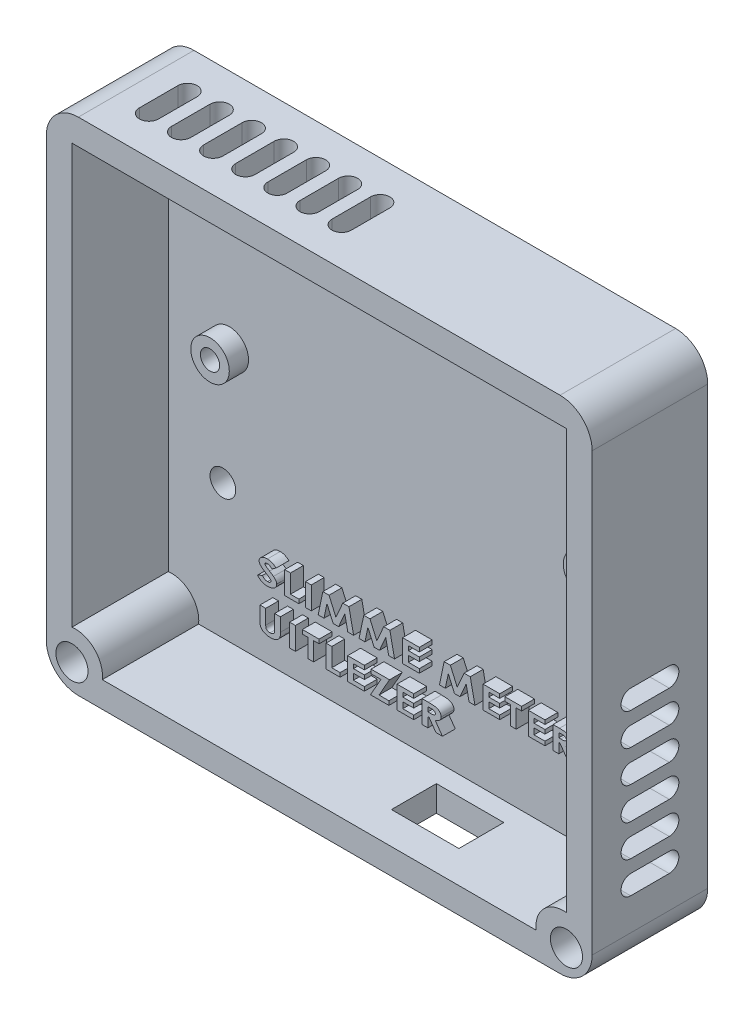
from build123d import *

# Parameters (mm, degrees)
SKETCH1_W                     = 85
SKETCH1_H                     = 78
SKETCH1_R                     = 1.5
BASE_PLATE_DEPTH              = 3
SKETCH2_R                     = 3
SKETCH2_R_2                   = 1.5
PI_ZERO_STAANDERS_DEPTH       = 3
SKETCH3_W                     = 85
SKETCH3_H                     = 78
SKETCH3_W_2                   = 77
SKETCH3_H_2                   = 70
BASE_WALLS_DEPTH              = 15
SKETCH5_W                     = 10.5
SKETCH5_H                     = 7
USB_POWER_UITSNEDE_DEPTH      = 4
FILLET1_R                     = 5
FILLET2_R                     = 5
FILLET3_R                     = 5
FILLET4_R                     = 5
LUCHT_VENTILATIE_RECHTS_DEPTH = 4
SKETCH10_R                    = 2
HOLES_FOR_SCREW_DEPTH         = 4
COOL_HOLES_DEPTH              = 4
SKETCH15_R                    = 4.25
SKETCH15_R_2                  = 1.475
SCREW_HOLES_DEPTH             = 15
SKETCH17_W                    = 0.897435898
SKETCH17_H                    = 3.5
SKETCH17_W_2                  = 0.897435897
TEKST_DEPTH                   = 2
SKETCH18_W                    = 15
SKETCH18_H                    = 2.5
CUT_EXTRUDE1_DEPTH            = 2.5
SKETCH19_R                    = 2.5
CUT_EXTRUDE2_DEPTH            = 16


with BuildPart() as part:
    # Sketch1 → Base Plate (new body)
    with BuildSketch(Plane.XY):
        with Locations((32.5, -1)):
            Rectangle(SKETCH1_W, SKETCH1_H)
        with BuildLine():
            Line((0, 3), (0, 27))
            ThreePointArc((0, 27), (0.878679656, 29.121320344), (3, 30))
            Line((3, 30), (62, 30))
            ThreePointArc((62, 30), (64.121320344, 29.121320344), (65, 27))
            Line((65, 27), (65, 3))
            ThreePointArc((65, 3), (64.121320344, 0.878679656), (62, 0))
            Line((62, 0), (3, 0))
            ThreePointArc((3, 0), (0.878679656, 0.878679656), (0, 3))
        make_face(mode=Mode.SUBTRACT)
        with BuildLine():
            ThreePointArc((0, 27), (0.878679656, 29.121320344), (3, 30))
            Line((3, 30), (62, 30))
            ThreePointArc((62, 30), (64.121320344, 29.121320344), (65, 27))
            Line((65, 27), (65, 3))
            ThreePointArc((65, 3), (64.121320344, 0.878679656), (62, 0))
            Line((62, 0), (3, 0))
            ThreePointArc((3, 0), (0.878679656, 0.878679656), (0, 3))
            Line((0, 3), (0, 27))
        make_face()
        with Locations((61.5, 26.5)):
            Circle(SKETCH1_R, mode=Mode.SUBTRACT)
        with Locations((3.5, 26.5)):
            Circle(SKETCH1_R, mode=Mode.SUBTRACT)
        with Locations((61.5, 3.5)):
            Circle(SKETCH1_R, mode=Mode.SUBTRACT)
        with Locations((3.5, 3.5)):
            Circle(SKETCH1_R, mode=Mode.SUBTRACT)
    extrude(amount=BASE_PLATE_DEPTH)

    # Sketch2 → Pi Zero Staanders (add)
    with BuildSketch(Plane.XY.offset(3)):
        with Locations((3.5, 26.5)):
            Circle(SKETCH2_R)
        with Locations((3.5, 26.5)):
            Circle(SKETCH2_R_2, mode=Mode.SUBTRACT)
        with Locations((3.5, 3.5)):
            Circle(SKETCH2_R)
        with Locations((3.5, 3.5)):
            Circle(SKETCH2_R_2, mode=Mode.SUBTRACT)
        with Locations((61.5, 26.5)):
            Circle(SKETCH2_R)
        with Locations((61.5, 26.5)):
            Circle(SKETCH2_R_2, mode=Mode.SUBTRACT)
        with Locations((61.5, 3.5)):
            Circle(SKETCH2_R)
        with Locations((61.5, 3.5)):
            Circle(SKETCH2_R_2, mode=Mode.SUBTRACT)
    extrude(amount=PI_ZERO_STAANDERS_DEPTH)

    # Sketch3 → Base Walls (add)
    with BuildSketch(Plane.XY.offset(3)):
        with Locations((32.5, -1)):
            Rectangle(SKETCH3_W, SKETCH3_H)
        with Locations((32.5, -1)):
            Rectangle(SKETCH3_W_2, SKETCH3_H_2, mode=Mode.SUBTRACT)
    extrude(amount=BASE_WALLS_DEPTH)

    # Sketch5 → USB Power uitsnede (cut)
    with BuildSketch(Plane.XZ.offset(40)):
        with Locations((44, 9.5)):
            Rectangle(SKETCH5_W, SKETCH5_H)
    extrude(amount=-USB_POWER_UITSNEDE_DEPTH, mode=Mode.SUBTRACT)

    # Fillet1
    fillet1_edges = [part.edges().sort_by_distance(p)[0] for p in [
        (75, 38, 9),
    ]]
    fillet(fillet1_edges, radius=FILLET1_R)

    # Fillet2
    fillet2_edges = [part.edges().sort_by_distance(p)[0] for p in [
        (-10, 38, 9),
    ]]
    fillet(fillet2_edges, radius=FILLET2_R)

    # Fillet3
    fillet3_edges = [part.edges().sort_by_distance(p)[0] for p in [
        (-10, -40, 9),
    ]]
    fillet(fillet3_edges, radius=FILLET3_R)

    # Fillet4
    fillet4_edges = [part.edges().sort_by_distance(p)[0] for p in [
        (75, -40, 9),
    ]]
    fillet(fillet4_edges, radius=FILLET4_R)

    # Sketch9 → Lucht ventilatie Rechts (cut)
    with BuildSketch(Plane(origin=(75, 0, 0), x_dir=(0, 0, -1), z_dir=(1, 0, 0))):
        with BuildLine():
            Line((-12, -27), (-6, -27))
            ThreePointArc((-6, -27), (-4.5, -28.5), (-6, -30))
            Line((-6, -30), (-12, -30))
            ThreePointArc((-12, -30), (-13.5, -28.5), (-12, -27))
        make_face()
        with BuildLine():
            Line((-12, -22), (-6, -22))
            ThreePointArc((-6, -22), (-4.5, -23.5), (-6, -25))
            Line((-6, -25), (-12, -25))
            ThreePointArc((-12, -25), (-13.5, -23.5), (-12, -22))
        make_face()
        with BuildLine():
            Line((-12, -17), (-6, -17))
            ThreePointArc((-6, -17), (-4.5, -18.5), (-6, -20))
            Line((-6, -20), (-12, -20))
            ThreePointArc((-12, -20), (-13.5, -18.5), (-12, -17))
        make_face()
        with BuildLine():
            Line((-12, -12), (-6, -12))
            ThreePointArc((-6, -12), (-4.5, -13.5), (-6, -15))
            Line((-6, -15), (-12, -15))
            ThreePointArc((-12, -15), (-13.5, -13.5), (-12, -12))
        make_face()
        with BuildLine():
            Line((-12, -7), (-6, -7))
            ThreePointArc((-6, -7), (-4.5, -8.5), (-6, -10))
            Line((-6, -10), (-12, -10))
            ThreePointArc((-12, -10), (-13.5, -8.5), (-12, -7))
        make_face()
        with BuildLine():
            Line((-12, -2), (-6, -2))
            ThreePointArc((-6, -2), (-4.5, -3.5), (-6, -5))
            Line((-6, -5), (-12, -5))
            ThreePointArc((-12, -5), (-13.5, -3.5), (-12, -2))
        make_face()
    extrude(amount=-LUCHT_VENTILATIE_RECHTS_DEPTH, mode=Mode.SUBTRACT)

    # Sketch10 → Holes for screw (cut, through all)
    with BuildSketch(Plane.XY.offset(3)):
        with Locations((2.5, -15.071619109)):
            Circle(SKETCH10_R)
        with Locations((62.5, -15.071619109)):
            Circle(SKETCH10_R)
    extrude(amount=-HOLES_FOR_SCREW_DEPTH, mode=Mode.SUBTRACT)

    # Sketch11 → Cool holes (cut)
    with BuildSketch(Plane(origin=(0, 38, 0), x_dir=(1, 0, 0), z_dir=(0, 1, 0))):
        with BuildLine():
            Line((-1.5, -12), (-1.5, -6))
            ThreePointArc((-1.5, -6), (0, -4.5), (1.5, -6))
            Line((1.5, -6), (1.5, -12))
            ThreePointArc((1.5, -12), (0, -13.5), (-1.5, -12))
        make_face()
        with BuildLine():
            Line((6.5, -12), (6.5, -6))
            ThreePointArc((6.5, -6), (5, -4.5), (3.5, -6))
            Line((3.5, -6), (3.5, -12))
            ThreePointArc((3.5, -12), (5, -13.5), (6.5, -12))
        make_face()
        with BuildLine():
            Line((11.5, -12), (11.5, -6))
            ThreePointArc((11.5, -6), (10, -4.5), (8.5, -6))
            Line((8.5, -6), (8.5, -12))
            ThreePointArc((8.5, -12), (10, -13.5), (11.5, -12))
        make_face()
        with BuildLine():
            Line((16.5, -12), (16.5, -6))
            ThreePointArc((16.5, -6), (15, -4.5), (13.5, -6))
            Line((13.5, -6), (13.5, -12))
            ThreePointArc((13.5, -12), (15, -13.5), (16.5, -12))
        make_face()
        with BuildLine():
            Line((21.5, -12), (21.5, -6))
            ThreePointArc((21.5, -6), (20, -4.5), (18.5, -6))
            Line((18.5, -6), (18.5, -12))
            ThreePointArc((18.5, -12), (20, -13.5), (21.5, -12))
        make_face()
        with BuildLine():
            Line((26.5, -12), (26.5, -6))
            ThreePointArc((26.5, -6), (25, -4.5), (23.5, -6))
            Line((23.5, -6), (23.5, -12))
            ThreePointArc((23.5, -12), (25, -13.5), (26.5, -12))
        make_face()
        with BuildLine():
            Line((31.5, -12), (31.5, -6))
            ThreePointArc((31.5, -6), (30, -4.5), (28.5, -6))
            Line((28.5, -6), (28.5, -12))
            ThreePointArc((28.5, -12), (30, -13.5), (31.5, -12))
        make_face()
    extrude(amount=-COOL_HOLES_DEPTH, mode=Mode.SUBTRACT)

    # Sketch15 → Screw Holes (add, through all)
    with BuildSketch(Plane.XY.offset(3)):
        with Locations((-5.5, -35.5)):
            Circle(SKETCH15_R)
        with Locations((-5.5, -35.5)):
            Circle(SKETCH15_R_2, mode=Mode.SUBTRACT)
        with Locations((70.5, -35.5)):
            Circle(SKETCH15_R)
        with Locations((70.5, -35.5)):
            Circle(SKETCH15_R_2, mode=Mode.SUBTRACT)
    extrude(amount=SCREW_HOLES_DEPTH)

    # Sketch17 → Tekst (add)
    with BuildSketch(Plane.XY.offset(3)):
        with BuildLine():
            Line((12.788368786, -20.420158139), (12.134222152, -20.8499458))
            add(Edge.make_bspline(
                [(12.134222152, -20.8499458), (12.105916214, -20.821431379), (12.050951664, -20.766061998), (11.963694483, -20.693193421), (11.876664006, -20.631001147), (11.789160013, -20.579670357), (11.700677894, -20.540288503), (11.611836758, -20.511997558), (11.522617657, -20.494221574), (11.462860439, -20.49205195), (11.433100357, -20.490971441)],
                knots=[0, 0, 0, 0, 0.000120481, 0.00023395, 0.000340557, 0.00044109, 0.000537763, 0.000630449, 0.000720379, 0.000809598, 0.000809598, 0.000809598, 0.000809598], degree=3))
            add(Edge.make_bspline(
                [(11.433100357, -20.490971441), (11.405466117, -20.491654327), (11.352414558, -20.492965316), (11.276603274, -20.506363161), (11.208550228, -20.528785971), (11.149327525, -20.559093295), (11.101410585, -20.594970072), (11.06484113, -20.633241503), (11.042918225, -20.675916041), (11.039853813, -20.705770617), (11.038368786, -20.720238268)],
                knots=[0, 0, 0, 0, 8.2839e-05, 0.000159033, 0.000229981, 0.000297088, 0.000357665, 0.000408789, 0.000454882, 0.000498222, 0.000498222, 0.000498222, 0.000498222], degree=3))
            add(Edge.make_bspline(
                [(11.038368786, -20.720238268), (11.039348383, -20.734844624), (11.041340854, -20.764553547), (11.057001056, -20.808208948), (11.082844522, -20.849964256), (11.105692489, -20.874844542), (11.117595549, -20.887806377)],
                knots=[0, 0, 0, 0, 4.3746e-05, 8.8978e-05, 0.000137436, 0.000190137, 0.000190137, 0.000190137, 0.000190137], degree=3))
            add(Edge.make_bspline(
                [(11.117595549, -20.887806377), (11.128669294, -20.89802759), (11.154557834, -20.921923056), (11.203176538, -20.958195785), (11.26361029, -21.004046625), (11.338514249, -21.056430713), (11.426515161, -21.116660228), (11.52870436, -21.183654088), (11.643319808, -21.259832032), (11.725137301, -21.311900521), (11.768236575, -21.339328812)],
                knots=[0, 0, 0, 0, 4.5183e-05, 0.00010563, 0.000181772, 0.000272813, 0.00037977, 0.000501695, 0.000639372, 0.000792627, 0.000792627, 0.000792627, 0.000792627], degree=3))
            add(Edge.make_bspline(
                [(11.768236575, -21.339328812), (11.808429466, -21.364810001), (11.884652078, -21.413133043), (11.992921082, -21.481617726), (12.0880721, -21.543756962), (12.171650258, -21.597044974), (12.241745962, -21.644526521), (12.300150365, -21.683703964), (12.346242598, -21.715351257), (12.37218663, -21.734925618), (12.383120389, -21.743174966)],
                knots=[0, 0, 0, 0, 0.000142769, 0.00027075, 0.000384323, 0.0004837, 0.000568094, 0.000638294, 0.000694698, 0.000735784, 0.000735784, 0.000735784, 0.000735784], degree=3))
            add(Edge.make_bspline(
                [(12.383120389, -21.743174966), (12.425227909, -21.776459178), (12.505352152, -21.839793999), (12.611420245, -21.939149829), (12.698531898, -22.036109743), (12.766093181, -22.132869437), (12.815999419, -22.231067786), (12.852784619, -22.331814659), (12.874065283, -22.437560088), (12.876756502, -22.509643027), (12.878112376, -22.545959421)],
                knots=[0, 0, 0, 0, 0.000160967, 0.000306295, 0.000435439, 0.000551351, 0.000659217, 0.000765002, 0.000872253, 0.000981153, 0.000981153, 0.000981153, 0.000981153], degree=3))
            add(Edge.make_bspline(
                [(12.878112376, -22.545959421), (12.876975922, -22.581347368), (12.874738763, -22.651010027), (12.854704867, -22.752861912), (12.824582363, -22.850458192), (12.779125936, -22.942273299), (12.722744754, -23.030216451), (12.652916809, -23.112809117), (12.570486179, -23.190376795), (12.477075351, -23.262737211), (12.373482538, -23.328299489), (12.261673913, -23.386024456), (12.141940626, -23.434433798), (12.014459102, -23.473502675), (11.879680457, -23.50416949), (11.737307353, -23.526659414), (11.587374634, -23.540092187), (11.484777531, -23.541523018), (11.432399235, -23.542253492)],
                knots=[0, 0, 0, 0, 0.000106057, 0.000208778, 0.000310332, 0.000411617, 0.000515079, 0.000623072, 0.000735155, 0.000854082, 0.000977008, 0.001102439, 0.001231073, 0.001363911, 0.001502016, 0.001645409, 0.001796039, 0.001953147, 0.001953147, 0.001953147, 0.001953147], degree=3))
            add(Edge.make_bspline(
                [(11.432399235, -23.542253492), (11.391252246, -23.541727972), (11.310039247, -23.540690738), (11.190229321, -23.532085671), (11.074377807, -23.518204189), (10.962708074, -23.498631063), (10.855038574, -23.473306618), (10.751261949, -23.442595364), (10.651495121, -23.406088678), (10.555586962, -23.363934965), (10.463527843, -23.315414657), (10.374973774, -23.260596032), (10.289966581, -23.199418612), (10.208185492, -23.13175347), (10.130058266, -23.057421686), (10.054521565, -22.97723656), (9.982935643, -22.890259727), (9.938877546, -22.828317951), (9.916573915, -22.796961024)],
                knots=[0, 0, 0, 0, 0.000123429, 0.000243616, 0.000360148, 0.000473342, 0.000583543, 0.000691797, 0.000797822, 0.000902042, 0.001005851, 0.001109749, 0.001214237, 0.001319807, 0.001427925, 0.001537545, 0.001650118, 0.001765533, 0.001765533, 0.001765533, 0.001765533], degree=3))
            Line((9.916573915, -22.796961024), (10.663969748, -22.465330415))
            add(Edge.make_bspline(
                [(10.663969748, -22.465330415), (10.692084405, -22.500928552), (10.746539267, -22.569878056), (10.836126775, -22.661340993), (10.928219985, -22.73946319), (11.02413009, -22.803220143), (11.123527353, -22.852772872), (11.226229705, -22.888192408), (11.332148831, -22.910057233), (11.404018456, -22.912714085), (11.440111575, -22.914048364)],
                knots=[0, 0, 0, 0, 0.000136005, 0.000263426, 0.000383359, 0.0004977, 0.00060807, 0.000715607, 0.000822858, 0.000931058, 0.000931058, 0.000931058, 0.000931058], degree=3))
            add(Edge.make_bspline(
                [(11.440111575, -22.914048364), (11.476907654, -22.912982622), (11.547754896, -22.910930642), (11.649251927, -22.891135297), (11.742392877, -22.861282613), (11.823270557, -22.81660095), (11.892156834, -22.766878122), (11.942075268, -22.709601268), (11.97498129, -22.647964535), (11.978796728, -22.604052093), (11.980676479, -22.582417755)],
                knots=[0, 0, 0, 0, 0.000110257, 0.000212289, 0.000309178, 0.000402346, 0.000488444, 0.000562514, 0.000628988, 0.000693541, 0.000693541, 0.000693541, 0.000693541], degree=3))
            add(Edge.make_bspline(
                [(11.980676479, -22.582417755), (11.979376133, -22.562338304), (11.976695861, -22.520950559), (11.951824217, -22.460460034), (11.914782914, -22.399868315), (11.87124146, -22.351145108), (11.827186512, -22.309964914), (11.784209708, -22.274639332), (11.733123331, -22.234427091), (11.672517578, -22.191411123), (11.603716064, -22.143520364), (11.526000304, -22.091665133), (11.438933833, -22.036586942), (11.377968021, -21.998580443), (11.346161254, -21.978751889)],
                knots=[0, 0, 0, 0, 6.0006e-05, 0.000123685, 0.000193548, 0.000272563, 0.000318694, 0.000374441, 0.000439377, 0.000513709, 0.00059734, 0.000690873, 0.000793957, 0.000906401, 0.000906401, 0.000906401, 0.000906401], degree=3))
            add(Edge.make_bspline(
                [(11.346161254, -21.978751889), (11.285546718, -21.941026987), (11.169234017, -21.868637003), (11.003683493, -21.762620192), (10.855450698, -21.662019307), (10.723781571, -21.568661292), (10.609183865, -21.481691843), (10.511185398, -21.401743277), (10.429645369, -21.328834771), (10.363700027, -21.2606673), (10.310966966, -21.195224797), (10.265494369, -21.13171828), (10.226841103, -21.068404548), (10.195761386, -21.004434416), (10.170808291, -20.941068871), (10.154239905, -20.877214925), (10.142930913, -20.813888841), (10.141596192, -20.771467988), (10.140932889, -20.750386505)],
                knots=[0, 0, 0, 0, 0.000214187, 0.000411001, 0.000589711, 0.000751578, 0.000895171, 0.001021211, 0.001130912, 0.001223146, 0.00130538, 0.001382809, 0.001457359, 0.001527598, 0.001595956, 0.001661262, 0.001725233, 0.001788432, 0.001788432, 0.001788432, 0.001788432], degree=3))
            add(Edge.make_bspline(
                [(10.140932889, -20.750386505), (10.141926567, -20.720383086), (10.143892734, -20.661016047), (10.162241958, -20.573689681), (10.191860643, -20.48983348), (10.232985486, -20.409278646), (10.285628443, -20.332155422), (10.349860691, -20.258292785), (10.426200062, -20.188327897), (10.512732211, -20.122082863), (10.607983464, -20.062011422), (10.709215507, -20.008165009), (10.816408526, -19.963485551), (10.928812094, -19.926080203), (11.04680702, -19.897526489), (11.170065622, -19.877224797), (11.29871462, -19.865259522), (11.386333648, -19.863608111), (11.430996992, -19.862766312)],
                knots=[0, 0, 0, 0, 8.9919e-05, 0.00017792, 0.000266398, 0.000356075, 0.000448445, 0.000545863, 0.000649059, 0.00075858, 0.000872365, 0.000986526, 0.001102158, 0.001220331, 0.001341577, 0.001465946, 0.001594804, 0.001728784, 0.001728784, 0.001728784, 0.001728784], degree=3))
            add(Edge.make_bspline(
                [(11.430996992, -19.862766312), (11.489033088, -19.864251496), (11.603906276, -19.867191181), (11.773982166, -19.890618358), (11.939847409, -19.927255984), (12.074819131, -19.97178314), (12.182034027, -20.015282681), (12.264170374, -20.054709724), (12.347504196, -20.100832373), (12.433381528, -20.151378226), (12.519360417, -20.210712101), (12.608503993, -20.273720408), (12.698382947, -20.344419212), (12.757897554, -20.394511232), (12.788368786, -20.420158139)],
                knots=[0, 0, 0, 0, 0.000174049, 0.000344503, 0.000514089, 0.000683037, 0.00077014, 0.000861083, 0.000956152, 0.001055832, 0.001159868, 0.001269409, 0.001383293, 0.001502776, 0.001502776, 0.001502776, 0.001502776], degree=3))
        make_face()
        Polygon((14.134522633, -19.952509902), (15.03195853, -19.952509902), (15.03195853, -22.824304774), (16.333240581, -22.824304774), (16.333240581, -23.452509902), (14.134522633, -23.452509902), align=None)
        with Locations((17.814009812, -21.702509902)):
            Rectangle(SKETCH17_W, SKETCH17_H)
        Polygon((20.066013017, -19.952509902), (21.032859972, -19.952509902), (22.099266222, -22.393815992), (23.171982568, -19.952509902), (24.131818306, -19.952509902), (24.858881607, -23.452509902), (23.949526639, -23.452509902), (23.490291863, -21.241872883), (22.518537056, -23.452509902), (21.674386415, -23.452509902), (20.708240581, -21.241872883), (20.249706927, -23.452509902), (19.339650838, -23.452509902), align=None)
        Polygon((26.437807889, -19.952509902), (27.404654844, -19.952509902), (28.471061094, -22.393815992), (29.54377744, -19.952509902), (30.503613177, -19.952509902), (31.230676479, -23.452509902), (30.321321511, -23.452509902), (29.862086735, -21.241872883), (28.890331927, -23.452509902), (28.046181286, -23.452509902), (27.080035453, -21.241872883), (26.621501799, -23.452509902), (25.711445709, -23.452509902), align=None)
        Polygon((32.487086735, -19.952509902), (35.089650838, -19.952509902), (35.089650838, -20.58071503), (33.384522633, -20.58071503), (33.384522633, -21.253791953), (35.089650838, -21.253791953), (35.089650838, -21.881997082), (33.384522633, -21.881997082), (33.384522633, -22.824304774), (35.089650838, -22.824304774), (35.089650838, -23.452509902), (32.487086735, -23.452509902), align=None)
        Polygon((38.957038658, -19.952509902), (39.923885613, -19.952509902), (40.990291863, -22.393815992), (42.063008209, -19.952509902), (43.022843947, -19.952509902), (43.749907248, -23.452509902), (42.84055228, -23.452509902), (42.381317504, -21.241872883), (41.409562697, -23.452509902), (40.565412056, -23.452509902), (39.599266222, -21.241872883), (39.140732568, -23.452509902), (38.230676479, -23.452509902), align=None)
        Polygon((45.006317504, -19.952509902), (47.608881607, -19.952509902), (47.608881607, -20.58071503), (45.903753402, -20.58071503), (45.903753402, -21.253791953), (47.608881607, -21.253791953), (47.608881607, -21.881997082), (45.903753402, -21.881997082), (45.903753402, -22.824304774), (47.608881607, -22.824304774), (47.608881607, -23.452509902), (45.006317504, -23.452509902), align=None)
        Polygon((48.416573915, -19.952509902), (51.019138017, -19.952509902), (51.019138017, -20.58071503), (50.166573915, -20.58071503), (50.166573915, -23.452509902), (49.269138017, -23.452509902), (49.269138017, -20.58071503), (48.416573915, -20.58071503), align=None)
        Polygon((52.051189299, -19.952509902), (54.653753402, -19.952509902), (54.653753402, -20.58071503), (52.948625197, -20.58071503), (52.948625197, -21.253791953), (54.653753402, -21.253791953), (54.653753402, -21.881997082), (52.948625197, -21.881997082), (52.948625197, -22.824304774), (54.653753402, -22.824304774), (54.653753402, -23.452509902), (52.051189299, -23.452509902), align=None)
        with BuildLine():
            Line((55.910163658, -19.952509902), (56.916273434, -19.952509902))
            add(Edge.make_bspline(
                [(56.916273434, -19.952509902), (56.982650164, -19.952689062), (57.110749362, -19.95303482), (57.295170316, -19.958171171), (57.464906505, -19.965535807), (57.619482799, -19.97645492), (57.759518085, -19.991249631), (57.884466354, -20.008340637), (57.994810489, -20.028328647), (58.091729998, -20.052382501), (58.179161315, -20.080447004), (58.260560877, -20.111729017), (58.337436882, -20.147933292), (58.410360455, -20.18745859), (58.478697836, -20.232219993), (58.543312448, -20.280187078), (58.603061821, -20.333228086), (58.658463457, -20.389656249), (58.707978567, -20.449848862), (58.752116476, -20.512614564), (58.789108048, -20.578415579), (58.819684086, -20.64687443), (58.842676813, -20.718183858), (58.859638611, -20.791799051), (58.869603635, -20.868370474), (58.870993844, -20.920262794), (58.87170212, -20.946700607)],
                knots=[0, 0, 0, 0, 0.000199124, 0.000384285, 0.000553431, 0.000708784, 0.000849082, 0.000975801, 0.00108705, 0.001185337, 0.001275138, 0.001362374, 0.001446748, 0.001529898, 0.001610992, 0.001691621, 0.001771099, 0.001850428, 0.001928618, 0.002004666, 0.002080325, 0.002154717, 0.002229214, 0.002304731, 0.002381085, 0.00246039, 0.00246039, 0.00246039, 0.00246039], degree=3))
            add(Edge.make_bspline(
                [(58.87170212, -20.946700607), (58.871140955, -20.974325217), (58.870037529, -21.028643815), (58.857999492, -21.108083243), (58.841047865, -21.184395476), (58.815426419, -21.257233204), (58.782446971, -21.326373033), (58.742738294, -21.392504284), (58.695838856, -21.454871887), (58.641020905, -21.513217862), (58.580173257, -21.569086319), (58.510552471, -21.620084873), (58.434551044, -21.668353268), (58.350727247, -21.712773202), (58.260007847, -21.753711055), (58.161988501, -21.791744573), (58.05667057, -21.826193571), (57.98325644, -21.845454158), (57.945520229, -21.855354453)],
                knots=[0, 0, 0, 0, 8.2807e-05, 0.000162824, 0.000240547, 0.000317046, 0.000393882, 0.000469995, 0.0005481, 0.000627479, 0.000709872, 0.00079555, 0.000885997, 0.000979782, 0.001079876, 0.001184428, 0.001295065, 0.001412085, 0.001412085, 0.001412085, 0.001412085], degree=3))
            Line((57.945520229, -21.855354453), (59.073625197, -23.452509902))
            Line((59.073625197, -23.452509902), (58.064009812, -23.452509902))
            Line((58.064009812, -23.452509902), (56.986385613, -21.926868877))
            Line((56.986385613, -21.926868877), (56.807599556, -21.926868877))
            Line((56.807599556, -21.926868877), (56.807599556, -23.452509902))
            Line((56.807599556, -23.452509902), (55.910163658, -23.452509902))
            Line((55.910163658, -23.452509902), (55.910163658, -19.952509902))
        make_face()
        with BuildLine():
            Line((56.807599556, -21.298663748), (57.125207729, -21.298663748))
            add(Edge.make_bspline(
                [(57.125207729, -21.298663748), (57.164003775, -21.298322294), (57.238574116, -21.29766598), (57.345701699, -21.294717231), (57.443180842, -21.287472409), (57.531090001, -21.278387806), (57.609910185, -21.267872687), (57.679112191, -21.252980914), (57.739326667, -21.236603321), (57.790596402, -21.216924636), (57.834354493, -21.194114243), (57.872005849, -21.168376442), (57.903218504, -21.138169466), (57.929758615, -21.105362866), (57.949261813, -21.067966337), (57.964307542, -21.028063009), (57.972793594, -20.984211731), (57.973762974, -20.953981162), (57.974266222, -20.938287146)],
                knots=[0, 0, 0, 0, 0.000116395, 0.000223724, 0.000321431, 0.000409544, 0.000488867, 0.000559823, 0.000621748, 0.000675912, 0.000724208, 0.000769526, 0.000812174, 0.000854113, 0.00089552, 0.00093811, 0.000981698, 0.001028757, 0.001028757, 0.001028757, 0.001028757], degree=3))
            add(Edge.make_bspline(
                [(57.974266222, -20.938287146), (57.973204698, -20.919702383), (57.971103166, -20.88290955), (57.953638401, -20.82968904), (57.923726346, -20.781418875), (57.884142258, -20.736985937), (57.834659536, -20.698129261), (57.777615911, -20.664402093), (57.712810502, -20.636893706), (57.652608784, -20.61947811), (57.597463795, -20.608746769), (57.547681436, -20.60094717), (57.490081229, -20.595066661), (57.4246648, -20.589224905), (57.351238394, -20.585256974), (57.269892956, -20.582455681), (57.180599494, -20.581275841), (57.118430298, -20.5809075), (57.085944908, -20.58071503)],
                knots=[0, 0, 0, 0, 5.5672e-05, 0.000110215, 0.000165887, 0.000224986, 0.000287837, 0.00035385, 0.000423265, 0.000498481, 0.000541382, 0.000591755, 0.000649592, 0.000715038, 0.000788775, 0.000870154, 0.000959207, 0.001056666, 0.001056666, 0.001056666, 0.001056666], degree=3))
            Line((57.085944908, -20.58071503), (56.807599556, -20.58071503))
            Line((56.807599556, -20.58071503), (56.807599556, -21.298663748))
        make_face(mode=Mode.SUBTRACT)
        with BuildLine():
            Line((10.275548274, -26.651227851), (11.172984171, -26.651227851))
            Line((11.172984171, -26.651227851), (11.172984171, -28.928471441))
            add(Edge.make_bspline(
                [(11.172984171, -28.928471441), (11.173376534, -28.952076457), (11.174134326, -28.99766607), (11.176431079, -29.0631958), (11.182150156, -29.123316008), (11.190063588, -29.177974967), (11.198501982, -29.227840918), (11.210566905, -29.272075953), (11.224299762, -29.310949738), (11.246171902, -29.355367242), (11.280245753, -29.405377843), (11.333817799, -29.45650182), (11.396386246, -29.503442497), (11.4706136, -29.542278858), (11.554233516, -29.573582889), (11.646356925, -29.596777463), (11.746832011, -29.609816494), (11.816342826, -29.61175932), (11.85237119, -29.612766312)],
                knots=[0, 0, 0, 0, 7.0827e-05, 0.000136792, 0.000196651, 0.00025188, 0.000302487, 0.000348237, 0.000389269, 0.000425956, 0.000496551, 0.00056943, 0.000647116, 0.000730549, 0.000819749, 0.000914465, 0.001014912, 0.001122996, 0.001122996, 0.001122996, 0.001122996], degree=3))
            add(Edge.make_bspline(
                [(11.85237119, -29.612766312), (11.89052608, -29.611956794), (11.964598632, -29.610385223), (12.071479212, -29.594487578), (12.170572322, -29.569862576), (12.26000014, -29.533925741), (12.339116111, -29.491146337), (12.40584126, -29.441912638), (12.460025753, -29.3873824), (12.494273624, -29.335235254), (12.514937903, -29.287999897), (12.528017487, -29.245633986), (12.53890912, -29.19609316), (12.548857786, -29.139779788), (12.555562759, -29.076052848), (12.560098914, -29.005408262), (12.564068774, -28.927579091), (12.564030017, -28.873322373), (12.564009812, -28.845037947)],
                knots=[0, 0, 0, 0, 0.000114388, 0.000222069, 0.000323419, 0.000420024, 0.000510393, 0.000592565, 0.000667928, 0.000739881, 0.000778181, 0.000822307, 0.000872651, 0.000930284, 0.000993773, 0.001064756, 0.00114266, 0.001227498, 0.001227498, 0.001227498, 0.001227498], degree=3))
            Line((12.564009812, -28.845037947), (12.564009812, -26.651227851))
            Line((12.564009812, -26.651227851), (13.461445709, -26.651227851))
            Line((13.461445709, -26.651227851), (13.461445709, -28.739168556))
            add(Edge.make_bspline(
                [(13.461445709, -28.739168556), (13.461118443, -28.78147045), (13.460489108, -28.862817375), (13.457349558, -28.979734566), (13.450711629, -29.086534734), (13.443214606, -29.183266823), (13.430637773, -29.26964136), (13.417981558, -29.346336674), (13.402268054, -29.413035774), (13.376616342, -29.489135354), (13.333655789, -29.577065531), (13.26506103, -29.677257322), (13.178710367, -29.775595698), (13.075795814, -29.870198926), (12.960073793, -29.958369512), (12.834068732, -30.03587692), (12.699245016, -30.100798643), (12.555122062, -30.152604472), (12.400761869, -30.193001848), (12.23499509, -30.2199047), (12.057511413, -30.238318631), (11.935154461, -30.240068358), (11.8720026, -30.240971441)],
                knots=[0, 0, 0, 0, 0.000126911, 0.000244051, 0.000350808, 0.000447928, 0.000534985, 0.00061256, 0.000681091, 0.000740289, 0.000853178, 0.000973355, 0.001103552, 0.001244951, 0.00139205, 0.001539354, 0.001687993, 0.001840142, 0.001998124, 0.002165949, 0.002343499, 0.002532885, 0.002532885, 0.002532885, 0.002532885], degree=3))
            add(Edge.make_bspline(
                [(11.8720026, -30.240971441), (11.829918507, -30.240475724), (11.747299742, -30.239502541), (11.625448773, -30.230558177), (11.507694229, -30.217669933), (11.393935709, -30.198715573), (11.284368703, -30.174225488), (11.178972362, -30.144138562), (11.077946613, -30.108228816), (10.981473347, -30.067793356), (10.890398837, -30.02305402), (10.805845971, -29.974721709), (10.727494382, -29.924154416), (10.655832676, -29.87101276), (10.591014758, -29.814871579), (10.533251098, -29.755630293), (10.481854133, -29.693941723), (10.436350177, -29.62825643), (10.397792916, -29.554847783), (10.365130136, -29.471540745), (10.337271662, -29.376969672), (10.314406258, -29.271285954), (10.297213195, -29.154140653), (10.284886783, -29.025909236), (10.277155154, -28.886264194), (10.27609729, -28.789426152), (10.275548274, -28.739168556)],
                knots=[0, 0, 0, 0, 0.000126233, 0.000247819, 0.000366358, 0.000481506, 0.0005936, 0.000703005, 0.000810111, 0.000915064, 0.001016657, 0.001114317, 0.00120708, 0.001296263, 0.001381742, 0.001464046, 0.00154421, 0.001622387, 0.001703305, 0.001792359, 0.001890406, 0.001998774, 0.002116473, 0.002245397, 0.002385133, 0.002535901, 0.002535901, 0.002535901, 0.002535901], degree=3))
            Line((10.275548274, -28.739168556), (10.275548274, -26.651227851))
        make_face()
        with Locations((15.350548274, -28.401227851)):
            Rectangle(SKETCH17_W_2, SKETCH17_H)
        Polygon((16.880676479, -26.651227851), (19.483240581, -26.651227851), (19.483240581, -27.279432979), (18.630676479, -27.279432979), (18.630676479, -30.151227851), (17.733240581, -30.151227851), (17.733240581, -27.279432979), (16.880676479, -27.279432979), align=None)
        Polygon((20.564650838, -26.651227851), (21.462086735, -26.651227851), (21.462086735, -29.523022723), (22.763368786, -29.523022723), (22.763368786, -30.151227851), (20.564650838, -30.151227851), align=None)
        Polygon((23.934522633, -26.651227851), (26.537086735, -26.651227851), (26.537086735, -27.279432979), (24.83195853, -27.279432979), (24.83195853, -27.952509902), (26.537086735, -27.952509902), (26.537086735, -28.58071503), (24.83195853, -28.58071503), (24.83195853, -29.523022723), (26.537086735, -29.523022723), (26.537086735, -30.151227851), (23.934522633, -30.151227851), align=None)
        Polygon((27.573625197, -26.651227851), (30.445420068, -26.651227851), (28.817415261, -29.523022723), (30.355676479, -29.523022723), (30.355676479, -30.151227851), (27.483881607, -30.151227851), (29.111886415, -27.279432979), (27.573625197, -27.279432979), align=None)
        Polygon((31.616573915, -26.651227851), (34.219138017, -26.651227851), (34.219138017, -27.279432979), (32.514009812, -27.279432979), (32.514009812, -27.952509902), (34.219138017, -27.952509902), (34.219138017, -28.58071503), (32.514009812, -28.58071503), (32.514009812, -29.523022723), (34.219138017, -29.523022723), (34.219138017, -30.151227851), (31.616573915, -30.151227851), align=None)
        with BuildLine():
            Line((35.524907248, -26.651227851), (36.531017024, -26.651227851))
            add(Edge.make_bspline(
                [(36.531017024, -26.651227851), (36.597393753, -26.651407011), (36.725492951, -26.651752769), (36.909913906, -26.65688912), (37.079650094, -26.664253755), (37.234226389, -26.675172869), (37.374261675, -26.689967579), (37.499209944, -26.707058586), (37.609554079, -26.727046596), (37.706473588, -26.751100449), (37.793904905, -26.779164953), (37.875304467, -26.810446965), (37.952180472, -26.846651241), (38.025104045, -26.886176539), (38.093441426, -26.930937942), (38.158056038, -26.978905026), (38.21780541, -27.031946035), (38.273207047, -27.088374198), (38.322722157, -27.148566811), (38.366860066, -27.211332512), (38.403851638, -27.277133528), (38.434427676, -27.345592379), (38.457420402, -27.416901807), (38.474382201, -27.490517), (38.484347225, -27.567088423), (38.485737434, -27.618980743), (38.486445709, -27.645418556)],
                knots=[0, 0, 0, 0, 0.000199124, 0.000384285, 0.000553431, 0.000708784, 0.000849082, 0.000975801, 0.00108705, 0.001185337, 0.001275138, 0.001362374, 0.001446748, 0.001529898, 0.001610992, 0.001691621, 0.001771099, 0.001850428, 0.001928618, 0.002004666, 0.002080325, 0.002154717, 0.002229214, 0.002304731, 0.002381085, 0.00246039, 0.00246039, 0.00246039, 0.00246039], degree=3))
            add(Edge.make_bspline(
                [(38.486445709, -27.645418556), (38.485884544, -27.673043165), (38.484781119, -27.727361764), (38.472743082, -27.806801192), (38.455791455, -27.883113424), (38.430170009, -27.955951153), (38.397190561, -28.025090982), (38.357481883, -28.091222232), (38.310582445, -28.153589836), (38.255764495, -28.211935811), (38.194916847, -28.267804267), (38.12529606, -28.318802822), (38.049294634, -28.367071217), (37.965470836, -28.411491151), (37.874751437, -28.452429003), (37.776732091, -28.490462522), (37.67141416, -28.52491152), (37.59800003, -28.544172107), (37.560263818, -28.554072402)],
                knots=[0, 0, 0, 0, 8.2807e-05, 0.000162824, 0.000240547, 0.000317046, 0.000393882, 0.000469995, 0.0005481, 0.000627479, 0.000709872, 0.00079555, 0.000885997, 0.000979782, 0.001079876, 0.001184428, 0.001295065, 0.001412085, 0.001412085, 0.001412085, 0.001412085], degree=3))
            Line((37.560263818, -28.554072402), (38.688368786, -30.151227851))
            Line((38.688368786, -30.151227851), (37.678753402, -30.151227851))
            Line((37.678753402, -30.151227851), (36.601129203, -28.625586825))
            Line((36.601129203, -28.625586825), (36.422343145, -28.625586825))
            Line((36.422343145, -28.625586825), (36.422343145, -30.151227851))
            Line((36.422343145, -30.151227851), (35.524907248, -30.151227851))
            Line((35.524907248, -30.151227851), (35.524907248, -26.651227851))
        make_face()
        with BuildLine():
            Line((36.422343145, -27.997381697), (36.739951318, -27.997381697))
            add(Edge.make_bspline(
                [(36.739951318, -27.997381697), (36.778747365, -27.997040242), (36.853317706, -27.996383929), (36.960445289, -27.99343518), (37.057924432, -27.986190358), (37.145833591, -27.977105754), (37.224653774, -27.966590636), (37.293855781, -27.951698863), (37.354070256, -27.93532127), (37.405339992, -27.915642584), (37.449098083, -27.892832192), (37.486749439, -27.867094391), (37.517962094, -27.836887415), (37.544502204, -27.804080814), (37.564005403, -27.766684286), (37.579051132, -27.726780958), (37.587537184, -27.682929679), (37.588506564, -27.65269911), (37.589009812, -27.637005094)],
                knots=[0, 0, 0, 0, 0.000116395, 0.000223724, 0.000321431, 0.000409544, 0.000488867, 0.000559823, 0.000621748, 0.000675912, 0.000724208, 0.000769526, 0.000812174, 0.000854113, 0.00089552, 0.00093811, 0.000981698, 0.001028757, 0.001028757, 0.001028757, 0.001028757], degree=3))
            add(Edge.make_bspline(
                [(37.589009812, -27.637005094), (37.587948288, -27.618420332), (37.585846756, -27.581627499), (37.56838199, -27.528406989), (37.538469936, -27.480136824), (37.498885848, -27.435703886), (37.449403126, -27.39684721), (37.3923595, -27.363120042), (37.327554092, -27.335611655), (37.267352374, -27.318196058), (37.212207384, -27.307464718), (37.162425025, -27.299665119), (37.104824819, -27.29378461), (37.039408389, -27.287942853), (36.965981984, -27.283974922), (36.884636546, -27.28117363), (36.795343084, -27.27999379), (36.733173887, -27.279625449), (36.700688498, -27.279432979)],
                knots=[0, 0, 0, 0, 5.5672e-05, 0.000110215, 0.000165887, 0.000224986, 0.000287837, 0.00035385, 0.000423265, 0.000498481, 0.000541382, 0.000591755, 0.000649592, 0.000715038, 0.000788775, 0.000870154, 0.000959207, 0.001056666, 0.001056666, 0.001056666, 0.001056666], degree=3))
            Line((36.700688498, -27.279432979), (36.422343145, -27.279432979))
            Line((36.422343145, -27.279432979), (36.422343145, -27.997381697))
        make_face(mode=Mode.SUBTRACT)
    extrude(amount=TEKST_DEPTH)

    # Sketch18 → Cut-Extrude1 (cut)
    with BuildSketch(Plane.XZ.offset(-34)):
        with Locations((52.5, 15.75)):
            Rectangle(SKETCH18_W, SKETCH18_H)
    extrude(amount=-CUT_EXTRUDE1_DEPTH, mode=Mode.SUBTRACT)

    # Sketch19 → Cut-Extrude2 (cut)
    with BuildSketch(Plane.XY.offset(18)):
        with Locations((71, -36)):
            Circle(SKETCH19_R)
        with Locations((-6, -36)):
            Circle(SKETCH19_R)
    extrude(amount=-CUT_EXTRUDE2_DEPTH, mode=Mode.SUBTRACT)


solid = part.part
